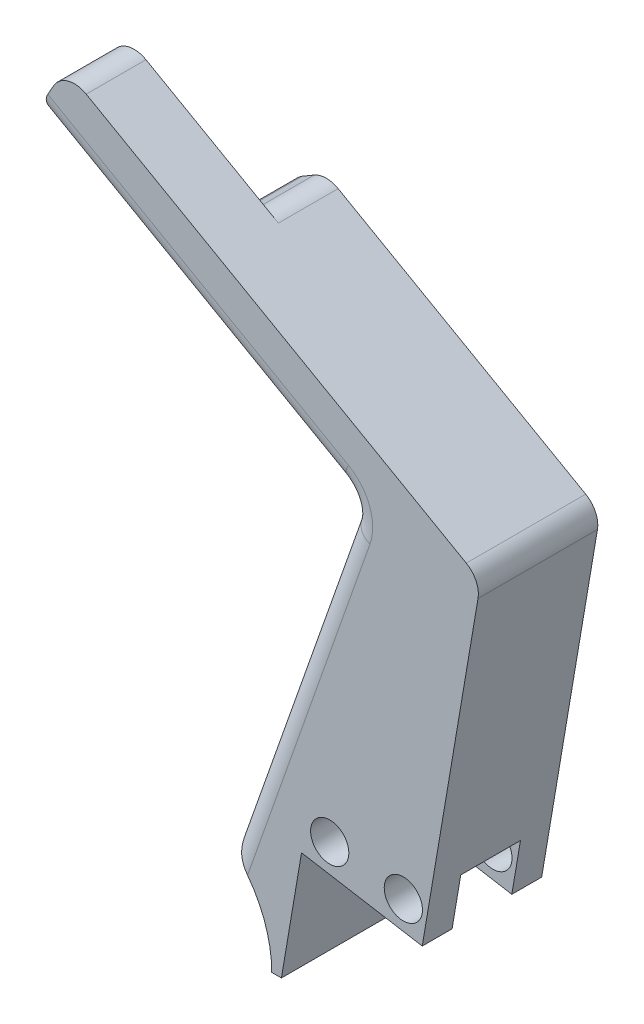
from build123d import *

# Parameters (mm, degrees)
SKETCH3_R           = 2.032
BOSS_EXTRUDE1_DEPTH = 12.7
SKETCH4_W           = 6.35
SKETCH4_H           = 5.498034445
CUT_EXTRUDE1_DEPTH  = 13.0175
CUT_EXTRUDE2_DEPTH  = 6.35
FILLET1_R           = 2.54


with BuildPart() as part:
    # Sketch3 → Boss-Extrude1 (new body)
    with BuildSketch(Plane.XY):
        with BuildLine():
            Line((-70.84525545, 66.890422126), (-58.01103717, 64.713693529))
            Line((-58.01103717, 64.713693529), (-51.782586103, 101.43728904))
            Line((-51.782586103, 101.43728904), (-95.941552678, 126.549550409))
            Line((-95.941552678, 126.549550409), (-99.080585349, 121.029679588))
            Line((-99.080585349, 121.029679588), (-65.256808444, 101.794819897))
            Line((-65.256808444, 101.794819897), (-78.546820512, 64.018247195))
            ThreePointArc((-78.546820512, 64.018247195), (-75.200114259, 59.656734692), (-74.010223155, 54.289482767))
            Line((-74.010223155, 54.289482767), (-72.982419121, 54.289482767))
            Line((-72.982419121, 54.289482767), (-70.84525545, 66.890422126))
        make_face()
        with Locations((-67.846388341, 69.382080978)):
            Circle(SKETCH3_R, mode=Mode.SUBTRACT)
        with Locations((-60.020645487, 68.054807443)):
            Circle(SKETCH3_R, mode=Mode.SUBTRACT)
    extrude(amount=BOSS_EXTRUDE1_DEPTH)

    # Sketch4 → Cut-Extrude1 (cut)
    with BuildSketch(Plane(origin=(-67.057766981, 11.373233325, 0), x_dir=(0, 0, -1), z_dir=(0.98592036, -0.167215563, 0))):
        with Locations((-6.35, 56.851216947)):
            Rectangle(SKETCH4_W, SKETCH4_H)
    extrude(amount=-CUT_EXTRUDE1_DEPTH, mode=Mode.SUBTRACT)

    # Sketch5 → Cut-Extrude2 (cut)
    with BuildSketch(Plane(origin=(0, 0, 0), x_dir=(-1, 0, 0), z_dir=(0, 0, -1))):
        Polygon((99.080585349, 121.029679588), (95.941552678, 126.549550409), (80.927504042, 118.011381544), (87.253435619, 114.30383208), align=None)
    extrude(amount=-CUT_EXTRUDE2_DEPTH, mode=Mode.SUBTRACT)

    # Fillet1
    fillet1_edges = [part.edges().sort_by_distance(p)[0] for p in [
        (-71.901814478, 82.906533546, 0),
        (-76.255122031, 108.049325988, 0),
        (-78.546820512, 64.018247195, 6.35),
        (-65.256808444, 101.794819897, 6.35),
        (-99.080585349, 121.029679588, 9.525),
        (-95.941552678, 126.549550409, 9.525),
        (-51.782586103, 101.43728904, 6.35),
        (-82.168696896, 111.412249742, 12.7),
        (-71.901814478, 82.906533546, 12.7),
        (-87.253435619, 114.30383208, 3.175),
        (-80.927504042, 118.011381544, 3.175),
    ]]
    fillet(fillet1_edges, radius=FILLET1_R)


solid = part.part
